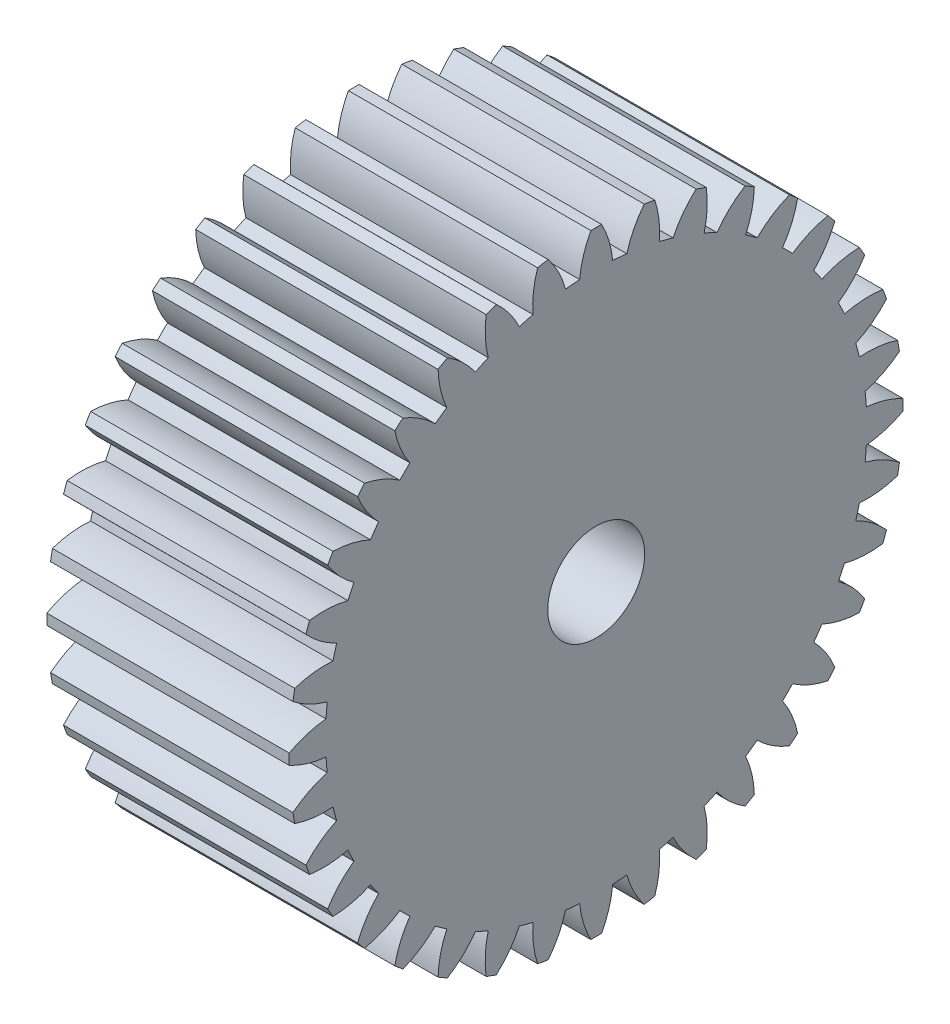
from build123d import *

# Parameters (mm, degrees)
SKETCH1_W           = 15
SKETCH1_H           = 19
CUT_EXTRUDE1_DEPTH  = 16
CUT_EXTRUDE2_DEPTH  = 16
CUT_EXTRUDE3_DEPTH  = 16
CUT_EXTRUDE4_DEPTH  = 16
CUT_EXTRUDE5_DEPTH  = 16
CUT_EXTRUDE6_DEPTH  = 16
CUT_EXTRUDE7_DEPTH  = 16
CUT_EXTRUDE8_DEPTH  = 16
CUT_EXTRUDE9_DEPTH  = 16
CUT_EXTRUDE10_DEPTH = 16
CUT_EXTRUDE11_DEPTH = 16
CUT_EXTRUDE12_DEPTH = 16
CUT_EXTRUDE13_DEPTH = 16
CUT_EXTRUDE14_DEPTH = 16
CUT_EXTRUDE15_DEPTH = 16
CUT_EXTRUDE16_DEPTH = 16
CUT_EXTRUDE17_DEPTH = 16
CUT_EXTRUDE18_DEPTH = 16
CUT_EXTRUDE19_DEPTH = 16
CUT_EXTRUDE20_DEPTH = 16
CUT_EXTRUDE21_DEPTH = 16
CUT_EXTRUDE22_DEPTH = 16
CUT_EXTRUDE23_DEPTH = 16
CUT_EXTRUDE24_DEPTH = 16
CUT_EXTRUDE25_DEPTH = 16
CUT_EXTRUDE26_DEPTH = 16
CUT_EXTRUDE27_DEPTH = 16
CUT_EXTRUDE28_DEPTH = 16
CUT_EXTRUDE29_DEPTH = 16
CUT_EXTRUDE30_DEPTH = 16
CUT_EXTRUDE31_DEPTH = 16
CUT_EXTRUDE32_DEPTH = 16
CUT_EXTRUDE33_DEPTH = 16
CUT_EXTRUDE34_DEPTH = 16
CUT_EXTRUDE35_DEPTH = 16
CUT_EXTRUDE36_DEPTH = 16
SKETCH46_R          = 3
CUT_EXTRUDE37_DEPTH = 16


with BuildPart() as part:
    # Sketch1 → Revolve1 (revolve)
    with BuildSketch(Plane.XY):
        with Locations((-1.5, 9.5)):
            Rectangle(SKETCH1_W, SKETCH1_H)
    revolve(axis=Axis((-9, 0, 0), (1, 0, 0)))

    # Sketch2 → Cut-Extrude1 (cut, through all)
    with BuildSketch(Plane.ZY.offset(9)):
        with BuildLine():
            ThreePointArc((18.766078471, -2.972254836), (18.927699264, -1.655959112), (18.997106208, -0.331595722))
            ThreePointArc((18.997106208, -0.331595722), (17.89254839, -0.79122096), (16.718757874, -1.022563037))
            ThreePointArc((16.718757874, -1.022563037), (16.686261193, -1.459858691), (16.642328583, -1.896153831))
            ThreePointArc((16.642328583, -1.896153831), (17.758114453, -2.327807886), (18.766078471, -2.972254836))
        make_face()
    extrude(amount=-CUT_EXTRUDE1_DEPTH, mode=Mode.SUBTRACT)

    # Sketch3 → Cut-Extrude2 (cut, through all)
    with BuildSketch(Plane.ZY.offset(9)):
        with BuildLine():
            ThreePointArc((17.964852936, -6.185794935), (18.352590699, -4.917561857), (18.650916486, -3.625370912))
            ThreePointArc((18.650916486, -3.625370912), (17.483326298, -3.886208957), (16.287196167, -3.910209845))
            ThreePointArc((16.287196167, -3.910209845), (16.17925759, -4.335219005), (16.060230559, -4.757257024))
            ThreePointArc((16.060230559, -4.757257024), (17.084109195, -5.376107468), (17.964852936, -6.185794935))
        make_face()
    extrude(amount=-CUT_EXTRUDE2_DEPTH, mode=Mode.SUBTRACT)

    # Sketch4 → Cut-Extrude3 (cut, through all)
    with BuildSketch(Plane.ZY.offset(9)):
        with BuildLine():
            ThreePointArc((16.617774436, -9.211382785), (17.219847954, -8.029746973), (17.738028103, -6.808991041))
            ThreePointArc((17.738028103, -6.808991041), (16.542882183, -6.863116462), (15.360756246, -6.679046904))
            ThreePointArc((15.360756246, -6.679046904), (15.180655433, -7.078855884), (14.990150557, -7.47381337))
            ThreePointArc((14.990150557, -7.47381337), (15.891011924, -8.261056744), (16.617774436, -9.211382785))
        make_face()
    extrude(amount=-CUT_EXTRUDE3_DEPTH, mode=Mode.SUBTRACT)

    # Sketch5 → Cut-Extrude4 (cut, through all)
    with BuildSketch(Plane.ZY.offset(9)):
        with BuildLine():
            ThreePointArc((14.765773268, -11.95708743), (15.563888841, -10.897952291), (16.286178713, -9.785723423))
            ThreePointArc((16.286178713, -9.785723423), (15.099790964, -9.631491646), (13.96758752, -9.244944504))
            ThreePointArc((13.96758752, -9.244944504), (13.720796742, -9.607405309), (13.464602415, -9.963281678))
            ThreePointArc((13.464602415, -9.963281678), (14.215074297, -10.894997991), (14.765773268, -11.95708743))
        make_face()
    extrude(amount=-CUT_EXTRUDE4_DEPTH, mode=Mode.SUBTRACT)

    # Sketch6 → Cut-Extrude5 (cut, through all)
    with BuildSketch(Plane.ZY.offset(9)):
        with BuildLine():
            ThreePointArc((12.465121551, -14.339482024), (13.435028843, -13.435028843), (14.339482024, -12.465121551))
            ThreePointArc((14.339482024, -12.465121551), (13.197900238, -12.10721883), (12.150020714, -11.529939143))
            ThreePointArc((12.150020714, -11.529939143), (11.844038585, -11.844038585), (11.529939143, -12.150020714))
            ThreePointArc((11.529939143, -12.150020714), (12.10721883, -13.197900238), (12.465121551, -14.339482024))
        make_face()
    extrude(amount=-CUT_EXTRUDE5_DEPTH, mode=Mode.SUBTRACT)

    # Sketch7 → Cut-Extrude6 (cut, through all)
    with BuildSketch(Plane.ZY.offset(9)):
        with BuildLine():
            ThreePointArc((9.785723423, -16.286178713), (10.897952291, -15.563888841), (11.95708743, -14.765773268))
            ThreePointArc((11.95708743, -14.765773268), (10.894997991, -14.215074297), (9.963281678, -13.464602415))
            ThreePointArc((9.963281678, -13.464602415), (9.607405309, -13.720796742), (9.244944504, -13.96758752))
            ThreePointArc((9.244944504, -13.96758752), (9.631491646, -15.099790964), (9.785723423, -16.286178713))
        make_face()
    extrude(amount=-CUT_EXTRUDE6_DEPTH, mode=Mode.SUBTRACT)

    # Sketch8 → Cut-Extrude7 (cut, through all)
    with BuildSketch(Plane.ZY.offset(9)):
        with BuildLine():
            ThreePointArc((6.808991041, -17.738028103), (8.029746973, -17.219847954), (9.211382785, -16.617774436))
            ThreePointArc((9.211382785, -16.617774436), (8.261056744, -15.891011924), (7.47381337, -14.990150557))
            ThreePointArc((7.47381337, -14.990150557), (7.078855884, -15.180655433), (6.679046904, -15.360756246))
            ThreePointArc((6.679046904, -15.360756246), (6.863116462, -16.542882183), (6.808991041, -17.738028103))
        make_face()
    extrude(amount=-CUT_EXTRUDE7_DEPTH, mode=Mode.SUBTRACT)

    # Sketch9 → Cut-Extrude8 (cut, through all)
    with BuildSketch(Plane.ZY.offset(9)):
        with BuildLine():
            ThreePointArc((3.625370912, -18.650916486), (4.917561857, -18.352590699), (6.185794935, -17.964852936))
            ThreePointArc((6.185794935, -17.964852936), (5.376107468, -17.084109195), (4.757257024, -16.060230559))
            ThreePointArc((4.757257024, -16.060230559), (4.335219005, -16.17925759), (3.910209845, -16.287196167))
            ThreePointArc((3.910209845, -16.287196167), (3.886208957, -17.483326298), (3.625370912, -18.650916486))
        make_face()
    extrude(amount=-CUT_EXTRUDE8_DEPTH, mode=Mode.SUBTRACT)

    # Sketch10 → Cut-Extrude9 (cut, through all)
    with BuildSketch(Plane.ZY.offset(9)):
        with BuildLine():
            ThreePointArc((0.331595722, -18.997106208), (1.655959112, -18.927699264), (2.972254836, -18.766078471))
            ThreePointArc((2.972254836, -18.766078471), (2.327807886, -17.758114453), (1.896153831, -16.642328583))
            ThreePointArc((1.896153831, -16.642328583), (1.459858691, -16.686261193), (1.022563037, -16.718757874))
            ThreePointArc((1.022563037, -16.718757874), (0.79122096, -17.89254839), (0.331595722, -18.997106208))
        make_face()
    extrude(amount=-CUT_EXTRUDE9_DEPTH, mode=Mode.SUBTRACT)

    # Sketch11 → Cut-Extrude10 (cut, through all)
    with BuildSketch(Plane.ZY.offset(9)):
        with BuildLine():
            ThreePointArc((-2.972254836, -18.766078471), (-1.655959112, -18.927699264), (-0.331595722, -18.997106208))
            ThreePointArc((-0.331595722, -18.997106208), (-0.79122096, -17.89254839), (-1.022563037, -16.718757874))
            ThreePointArc((-1.022563037, -16.718757874), (-1.459858691, -16.686261193), (-1.896153831, -16.642328583))
            ThreePointArc((-1.896153831, -16.642328583), (-2.327807886, -17.758114453), (-2.972254836, -18.766078471))
        make_face()
    extrude(amount=-CUT_EXTRUDE10_DEPTH, mode=Mode.SUBTRACT)

    # Sketch12 → Cut-Extrude11 (cut, through all)
    with BuildSketch(Plane.ZY.offset(9)):
        with BuildLine():
            ThreePointArc((-6.185794935, -17.964852936), (-4.917561857, -18.352590699), (-3.625370912, -18.650916486))
            ThreePointArc((-3.625370912, -18.650916486), (-3.886208957, -17.483326298), (-3.910209845, -16.287196167))
            ThreePointArc((-3.910209845, -16.287196167), (-4.335219005, -16.17925759), (-4.757257024, -16.060230559))
            ThreePointArc((-4.757257024, -16.060230559), (-5.376107468, -17.084109195), (-6.185794935, -17.964852936))
        make_face()
    extrude(amount=-CUT_EXTRUDE11_DEPTH, mode=Mode.SUBTRACT)

    # Sketch13 → Cut-Extrude12 (cut, through all)
    with BuildSketch(Plane.ZY.offset(9)):
        with BuildLine():
            ThreePointArc((-9.211382785, -16.617774436), (-8.029746973, -17.219847954), (-6.808991041, -17.738028103))
            ThreePointArc((-6.808991041, -17.738028103), (-6.863116462, -16.542882183), (-6.679046904, -15.360756246))
            ThreePointArc((-6.679046904, -15.360756246), (-7.078855884, -15.180655433), (-7.47381337, -14.990150557))
            ThreePointArc((-7.47381337, -14.990150557), (-8.261056744, -15.891011924), (-9.211382785, -16.617774436))
        make_face()
    extrude(amount=-CUT_EXTRUDE12_DEPTH, mode=Mode.SUBTRACT)

    # Sketch14 → Cut-Extrude13 (cut, through all)
    with BuildSketch(Plane.ZY.offset(9)):
        with BuildLine():
            ThreePointArc((-11.95708743, -14.765773268), (-10.897952291, -15.563888841), (-9.785723423, -16.286178713))
            ThreePointArc((-9.785723423, -16.286178713), (-9.631491646, -15.099790964), (-9.244944504, -13.96758752))
            ThreePointArc((-9.244944504, -13.96758752), (-9.607405309, -13.720796742), (-9.963281678, -13.464602415))
            ThreePointArc((-9.963281678, -13.464602415), (-10.894997991, -14.215074297), (-11.95708743, -14.765773268))
        make_face()
    extrude(amount=-CUT_EXTRUDE13_DEPTH, mode=Mode.SUBTRACT)

    # Sketch15 → Cut-Extrude14 (cut, through all)
    with BuildSketch(Plane.ZY.offset(9)):
        with BuildLine():
            ThreePointArc((-14.339482024, -12.465121551), (-13.435028843, -13.435028843), (-12.465121551, -14.339482024))
            ThreePointArc((-12.465121551, -14.339482024), (-12.10721883, -13.197900238), (-11.529939143, -12.150020714))
            ThreePointArc((-11.529939143, -12.150020714), (-11.844038585, -11.844038585), (-12.150020714, -11.529939143))
            ThreePointArc((-12.150020714, -11.529939143), (-13.197900238, -12.10721883), (-14.339482024, -12.465121551))
        make_face()
    extrude(amount=-CUT_EXTRUDE14_DEPTH, mode=Mode.SUBTRACT)

    # Sketch16 → Cut-Extrude15 (cut, through all)
    with BuildSketch(Plane.ZY.offset(9)):
        with BuildLine():
            ThreePointArc((-16.286178713, -9.785723423), (-15.563888841, -10.897952291), (-14.765773268, -11.95708743))
            ThreePointArc((-14.765773268, -11.95708743), (-14.215074297, -10.894997991), (-13.464602415, -9.963281678))
            ThreePointArc((-13.464602415, -9.963281678), (-13.720796742, -9.607405309), (-13.96758752, -9.244944504))
            ThreePointArc((-13.96758752, -9.244944504), (-15.099790964, -9.631491646), (-16.286178713, -9.785723423))
        make_face()
    extrude(amount=-CUT_EXTRUDE15_DEPTH, mode=Mode.SUBTRACT)

    # Sketch17 → Cut-Extrude16 (cut, through all)
    with BuildSketch(Plane.ZY.offset(9)):
        with BuildLine():
            ThreePointArc((-17.738028103, -6.808991041), (-17.219847954, -8.029746973), (-16.617774436, -9.211382785))
            ThreePointArc((-16.617774436, -9.211382785), (-15.891011924, -8.261056744), (-14.990150557, -7.47381337))
            ThreePointArc((-14.990150557, -7.47381337), (-15.180655433, -7.078855884), (-15.360756246, -6.679046904))
            ThreePointArc((-15.360756246, -6.679046904), (-16.542882183, -6.863116462), (-17.738028103, -6.808991041))
        make_face()
    extrude(amount=-CUT_EXTRUDE16_DEPTH, mode=Mode.SUBTRACT)

    # Sketch18 → Cut-Extrude17 (cut, through all)
    with BuildSketch(Plane.ZY.offset(9)):
        with BuildLine():
            ThreePointArc((-18.650916486, -3.625370912), (-18.352590699, -4.917561857), (-17.964852936, -6.185794935))
            ThreePointArc((-17.964852936, -6.185794935), (-17.084109195, -5.376107468), (-16.060230559, -4.757257024))
            ThreePointArc((-16.060230559, -4.757257024), (-16.17925759, -4.335219005), (-16.287196167, -3.910209845))
            ThreePointArc((-16.287196167, -3.910209845), (-17.483326298, -3.886208957), (-18.650916486, -3.625370912))
        make_face()
    extrude(amount=-CUT_EXTRUDE17_DEPTH, mode=Mode.SUBTRACT)

    # Sketch19 → Cut-Extrude18 (cut, through all)
    with BuildSketch(Plane.ZY.offset(9)):
        with BuildLine():
            ThreePointArc((-18.997106208, -0.331595722), (-18.927699264, -1.655959112), (-18.766078471, -2.972254836))
            ThreePointArc((-18.766078471, -2.972254836), (-17.758114453, -2.327807886), (-16.642328583, -1.896153831))
            ThreePointArc((-16.642328583, -1.896153831), (-16.686261193, -1.459858691), (-16.718757874, -1.022563037))
            ThreePointArc((-16.718757874, -1.022563037), (-17.89254839, -0.79122096), (-18.997106208, -0.331595722))
        make_face()
    extrude(amount=-CUT_EXTRUDE18_DEPTH, mode=Mode.SUBTRACT)

    # Sketch20 → Cut-Extrude19 (cut, through all)
    with BuildSketch(Plane.ZY.offset(9)):
        with BuildLine():
            ThreePointArc((-18.766078471, 2.972254836), (-18.927699264, 1.655959112), (-18.997106208, 0.331595722))
            ThreePointArc((-18.997106208, 0.331595722), (-17.89254839, 0.79122096), (-16.718757874, 1.022563037))
            ThreePointArc((-16.718757874, 1.022563037), (-16.686261193, 1.459858691), (-16.642328583, 1.896153831))
            ThreePointArc((-16.642328583, 1.896153831), (-17.758114453, 2.327807886), (-18.766078471, 2.972254836))
        make_face()
    extrude(amount=-CUT_EXTRUDE19_DEPTH, mode=Mode.SUBTRACT)

    # Sketch21 → Cut-Extrude20 (cut, through all)
    with BuildSketch(Plane.ZY.offset(9)):
        with BuildLine():
            ThreePointArc((-17.964852936, 6.185794935), (-18.352590699, 4.917561857), (-18.650916486, 3.625370912))
            ThreePointArc((-18.650916486, 3.625370912), (-17.483326298, 3.886208957), (-16.287196167, 3.910209845))
            ThreePointArc((-16.287196167, 3.910209845), (-16.17925759, 4.335219005), (-16.060230559, 4.757257024))
            ThreePointArc((-16.060230559, 4.757257024), (-17.084109195, 5.376107468), (-17.964852936, 6.185794935))
        make_face()
    extrude(amount=-CUT_EXTRUDE20_DEPTH, mode=Mode.SUBTRACT)

    # Sketch22 → Cut-Extrude21 (cut, through all)
    with BuildSketch(Plane.ZY.offset(9)):
        with BuildLine():
            ThreePointArc((-16.617774436, 9.211382785), (-17.219847954, 8.029746973), (-17.738028103, 6.808991041))
            ThreePointArc((-17.738028103, 6.808991041), (-16.542882183, 6.863116462), (-15.360756246, 6.679046904))
            ThreePointArc((-15.360756246, 6.679046904), (-15.180655433, 7.078855884), (-14.990150557, 7.47381337))
            ThreePointArc((-14.990150557, 7.47381337), (-15.891011924, 8.261056744), (-16.617774436, 9.211382785))
        make_face()
    extrude(amount=-CUT_EXTRUDE21_DEPTH, mode=Mode.SUBTRACT)

    # Sketch23 → Cut-Extrude22 (cut, through all)
    with BuildSketch(Plane.ZY.offset(9)):
        with BuildLine():
            ThreePointArc((-14.765773268, 11.95708743), (-15.563888841, 10.897952291), (-16.286178713, 9.785723423))
            ThreePointArc((-16.286178713, 9.785723423), (-15.099790964, 9.631491646), (-13.96758752, 9.244944504))
            ThreePointArc((-13.96758752, 9.244944504), (-13.720796742, 9.607405309), (-13.464602415, 9.963281678))
            ThreePointArc((-13.464602415, 9.963281678), (-14.215074297, 10.894997991), (-14.765773268, 11.95708743))
        make_face()
    extrude(amount=-CUT_EXTRUDE22_DEPTH, mode=Mode.SUBTRACT)

    # Sketch24 → Cut-Extrude23 (cut, through all)
    with BuildSketch(Plane.ZY.offset(9)):
        with BuildLine():
            ThreePointArc((-12.465121551, 14.339482024), (-13.435028843, 13.435028843), (-14.339482024, 12.465121551))
            ThreePointArc((-14.339482024, 12.465121551), (-13.197900238, 12.10721883), (-12.150020714, 11.529939143))
            ThreePointArc((-12.150020714, 11.529939143), (-11.844038585, 11.844038585), (-11.529939143, 12.150020714))
            ThreePointArc((-11.529939143, 12.150020714), (-12.10721883, 13.197900238), (-12.465121551, 14.339482024))
        make_face()
    extrude(amount=-CUT_EXTRUDE23_DEPTH, mode=Mode.SUBTRACT)

    # Sketch25 → Cut-Extrude24 (cut, through all)
    with BuildSketch(Plane.ZY.offset(9)):
        with BuildLine():
            ThreePointArc((-9.785723423, 16.286178713), (-10.897952291, 15.563888841), (-11.95708743, 14.765773268))
            ThreePointArc((-11.95708743, 14.765773268), (-10.894997991, 14.215074297), (-9.963281678, 13.464602415))
            ThreePointArc((-9.963281678, 13.464602415), (-9.607405309, 13.720796742), (-9.244944504, 13.96758752))
            ThreePointArc((-9.244944504, 13.96758752), (-9.631491646, 15.099790964), (-9.785723423, 16.286178713))
        make_face()
    extrude(amount=-CUT_EXTRUDE24_DEPTH, mode=Mode.SUBTRACT)

    # Sketch26 → Cut-Extrude25 (cut, through all)
    with BuildSketch(Plane.ZY.offset(9)):
        with BuildLine():
            ThreePointArc((-6.808991041, 17.738028103), (-8.029746973, 17.219847954), (-9.211382785, 16.617774436))
            ThreePointArc((-9.211382785, 16.617774436), (-8.261056744, 15.891011924), (-7.47381337, 14.990150557))
            ThreePointArc((-7.47381337, 14.990150557), (-7.078855884, 15.180655433), (-6.679046904, 15.360756246))
            ThreePointArc((-6.679046904, 15.360756246), (-6.863116462, 16.542882183), (-6.808991041, 17.738028103))
        make_face()
    extrude(amount=-CUT_EXTRUDE25_DEPTH, mode=Mode.SUBTRACT)

    # Sketch27 → Cut-Extrude26 (cut, through all)
    with BuildSketch(Plane.ZY.offset(9)):
        with BuildLine():
            ThreePointArc((-3.625370912, 18.650916486), (-4.917561857, 18.352590699), (-6.185794935, 17.964852936))
            ThreePointArc((-6.185794935, 17.964852936), (-5.376107468, 17.084109195), (-4.757257024, 16.060230559))
            ThreePointArc((-4.757257024, 16.060230559), (-4.335219005, 16.17925759), (-3.910209845, 16.287196167))
            ThreePointArc((-3.910209845, 16.287196167), (-3.886208957, 17.483326298), (-3.625370912, 18.650916486))
        make_face()
    extrude(amount=-CUT_EXTRUDE26_DEPTH, mode=Mode.SUBTRACT)

    # Sketch28 → Cut-Extrude27 (cut, through all)
    with BuildSketch(Plane.ZY.offset(9)):
        with BuildLine():
            ThreePointArc((-0.331595722, 18.997106208), (-1.655959112, 18.927699264), (-2.972254836, 18.766078471))
            ThreePointArc((-2.972254836, 18.766078471), (-2.327807886, 17.758114453), (-1.896153831, 16.642328583))
            ThreePointArc((-1.896153831, 16.642328583), (-1.459858691, 16.686261193), (-1.022563037, 16.718757874))
            ThreePointArc((-1.022563037, 16.718757874), (-0.79122096, 17.89254839), (-0.331595722, 18.997106208))
        make_face()
    extrude(amount=-CUT_EXTRUDE27_DEPTH, mode=Mode.SUBTRACT)

    # Sketch29 → Cut-Extrude28 (cut, through all)
    with BuildSketch(Plane.ZY.offset(9)):
        with BuildLine():
            ThreePointArc((2.972254836, 18.766078471), (1.655959112, 18.927699264), (0.331595722, 18.997106208))
            ThreePointArc((0.331595722, 18.997106208), (0.79122096, 17.89254839), (1.022563037, 16.718757874))
            ThreePointArc((1.022563037, 16.718757874), (1.459858691, 16.686261193), (1.896153831, 16.642328583))
            ThreePointArc((1.896153831, 16.642328583), (2.327807886, 17.758114453), (2.972254836, 18.766078471))
        make_face()
    extrude(amount=-CUT_EXTRUDE28_DEPTH, mode=Mode.SUBTRACT)

    # Sketch30 → Cut-Extrude29 (cut, through all)
    with BuildSketch(Plane.ZY.offset(9)):
        with BuildLine():
            ThreePointArc((6.185794935, 17.964852936), (4.917561857, 18.352590699), (3.625370912, 18.650916486))
            ThreePointArc((3.625370912, 18.650916486), (3.886208957, 17.483326298), (3.910209845, 16.287196167))
            ThreePointArc((3.910209845, 16.287196167), (4.335219005, 16.17925759), (4.757257024, 16.060230559))
            ThreePointArc((4.757257024, 16.060230559), (5.376107468, 17.084109195), (6.185794935, 17.964852936))
        make_face()
    extrude(amount=-CUT_EXTRUDE29_DEPTH, mode=Mode.SUBTRACT)

    # Sketch31 → Cut-Extrude30 (cut, through all)
    with BuildSketch(Plane.ZY.offset(9)):
        with BuildLine():
            ThreePointArc((9.211382785, 16.617774436), (8.029746973, 17.219847954), (6.808991041, 17.738028103))
            ThreePointArc((6.808991041, 17.738028103), (6.863116462, 16.542882183), (6.679046904, 15.360756246))
            ThreePointArc((6.679046904, 15.360756246), (7.078855884, 15.180655433), (7.47381337, 14.990150557))
            ThreePointArc((7.47381337, 14.990150557), (8.261056744, 15.891011924), (9.211382785, 16.617774436))
        make_face()
    extrude(amount=-CUT_EXTRUDE30_DEPTH, mode=Mode.SUBTRACT)

    # Sketch32 → Cut-Extrude31 (cut, through all)
    with BuildSketch(Plane.ZY.offset(9)):
        with BuildLine():
            ThreePointArc((11.95708743, 14.765773268), (10.897952291, 15.563888841), (9.785723423, 16.286178713))
            ThreePointArc((9.785723423, 16.286178713), (9.631491646, 15.099790964), (9.244944504, 13.96758752))
            ThreePointArc((9.244944504, 13.96758752), (9.607405309, 13.720796742), (9.963281678, 13.464602415))
            ThreePointArc((9.963281678, 13.464602415), (10.894997991, 14.215074297), (11.95708743, 14.765773268))
        make_face()
    extrude(amount=-CUT_EXTRUDE31_DEPTH, mode=Mode.SUBTRACT)

    # Sketch33 → Cut-Extrude32 (cut, through all)
    with BuildSketch(Plane.ZY.offset(9)):
        with BuildLine():
            ThreePointArc((14.339482024, 12.465121551), (13.435028843, 13.435028843), (12.465121551, 14.339482024))
            ThreePointArc((12.465121551, 14.339482024), (12.10721883, 13.197900238), (11.529939143, 12.150020714))
            ThreePointArc((11.529939143, 12.150020714), (11.844038585, 11.844038585), (12.150020714, 11.529939143))
            ThreePointArc((12.150020714, 11.529939143), (13.197900238, 12.10721883), (14.339482024, 12.465121551))
        make_face()
    extrude(amount=-CUT_EXTRUDE32_DEPTH, mode=Mode.SUBTRACT)

    # Sketch34 → Cut-Extrude33 (cut, through all)
    with BuildSketch(Plane.ZY.offset(9)):
        with BuildLine():
            ThreePointArc((16.286178713, 9.785723423), (15.563888841, 10.897952291), (14.765773268, 11.95708743))
            ThreePointArc((14.765773268, 11.95708743), (14.215074297, 10.894997991), (13.464602415, 9.963281678))
            ThreePointArc((13.464602415, 9.963281678), (13.720796742, 9.607405309), (13.96758752, 9.244944504))
            ThreePointArc((13.96758752, 9.244944504), (15.099790964, 9.631491646), (16.286178713, 9.785723423))
        make_face()
    extrude(amount=-CUT_EXTRUDE33_DEPTH, mode=Mode.SUBTRACT)

    # Sketch35 → Cut-Extrude34 (cut, through all)
    with BuildSketch(Plane.ZY.offset(9)):
        with BuildLine():
            ThreePointArc((17.738028103, 6.808991041), (17.219847954, 8.029746973), (16.617774436, 9.211382785))
            ThreePointArc((16.617774436, 9.211382785), (15.891011924, 8.261056744), (14.990150557, 7.47381337))
            ThreePointArc((14.990150557, 7.47381337), (15.180655433, 7.078855884), (15.360756246, 6.679046904))
            ThreePointArc((15.360756246, 6.679046904), (16.542882183, 6.863116462), (17.738028103, 6.808991041))
        make_face()
    extrude(amount=-CUT_EXTRUDE34_DEPTH, mode=Mode.SUBTRACT)

    # Sketch36 → Cut-Extrude35 (cut, through all)
    with BuildSketch(Plane.ZY.offset(9)):
        with BuildLine():
            ThreePointArc((18.650916486, 3.625370912), (18.352590699, 4.917561857), (17.964852936, 6.185794935))
            ThreePointArc((17.964852936, 6.185794935), (17.084109195, 5.376107468), (16.060230559, 4.757257024))
            ThreePointArc((16.060230559, 4.757257024), (16.17925759, 4.335219005), (16.287196167, 3.910209845))
            ThreePointArc((16.287196167, 3.910209845), (17.483326298, 3.886208957), (18.650916486, 3.625370912))
        make_face()
    extrude(amount=-CUT_EXTRUDE35_DEPTH, mode=Mode.SUBTRACT)

    # Sketch37 → Cut-Extrude36 (cut, through all)
    with BuildSketch(Plane.ZY.offset(9)):
        with BuildLine():
            ThreePointArc((18.997106208, 0.331595722), (18.927699264, 1.655959112), (18.766078471, 2.972254836))
            ThreePointArc((18.766078471, 2.972254836), (17.758114453, 2.327807886), (16.642328583, 1.896153831))
            ThreePointArc((16.642328583, 1.896153831), (16.686261193, 1.459858691), (16.718757874, 1.022563037))
            ThreePointArc((16.718757874, 1.022563037), (17.89254839, 0.79122096), (18.997106208, 0.331595722))
        make_face()
    extrude(amount=-CUT_EXTRUDE36_DEPTH, mode=Mode.SUBTRACT)

    # Sketch46 → Cut-Extrude37 (cut, through all)
    with BuildSketch(Plane(origin=(6, 0, 0), x_dir=(0, 0, -1), z_dir=(1, 0, 0))):
        Circle(SKETCH46_R)
    extrude(amount=-CUT_EXTRUDE37_DEPTH, mode=Mode.SUBTRACT)


solid = part.part
